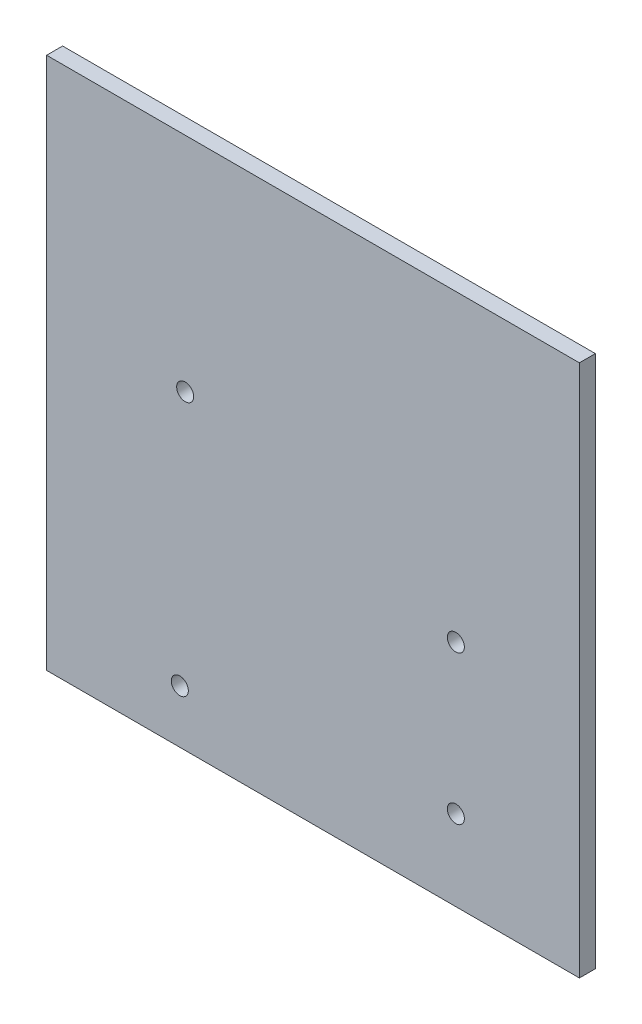
from build123d import *

# Parameters (mm, degrees)
SKETCH1_W           = 100
SKETCH1_H           = 100
BOSS_EXTRUDE1_DEPTH = 3
SKETCH2_R           = 1.6
CUT_EXTRUDE1_DEPTH  = 59


with BuildPart() as part:
    # Sketch1 → Boss-Extrude1 (new body)
    with BuildSketch(Plane.XY):
        Rectangle(SKETCH1_W, SKETCH1_H)
    extrude(amount=BOSS_EXTRUDE1_DEPTH)

    # Sketch2 → Cut-Extrude1 (cut)
    with BuildSketch(Plane.XY.offset(3)):
        with Locations((26.807477417, -34.9)):
            Circle(SKETCH2_R)
        with Locations((26.807477417, -7)):
            Circle(SKETCH2_R)
        with Locations((-25, -40)):
            Circle(SKETCH2_R)
        with Locations((-23.992522583, 8.289491499)):
            Circle(SKETCH2_R)
    extrude(amount=-CUT_EXTRUDE1_DEPTH, mode=Mode.SUBTRACT)


solid = part.part
